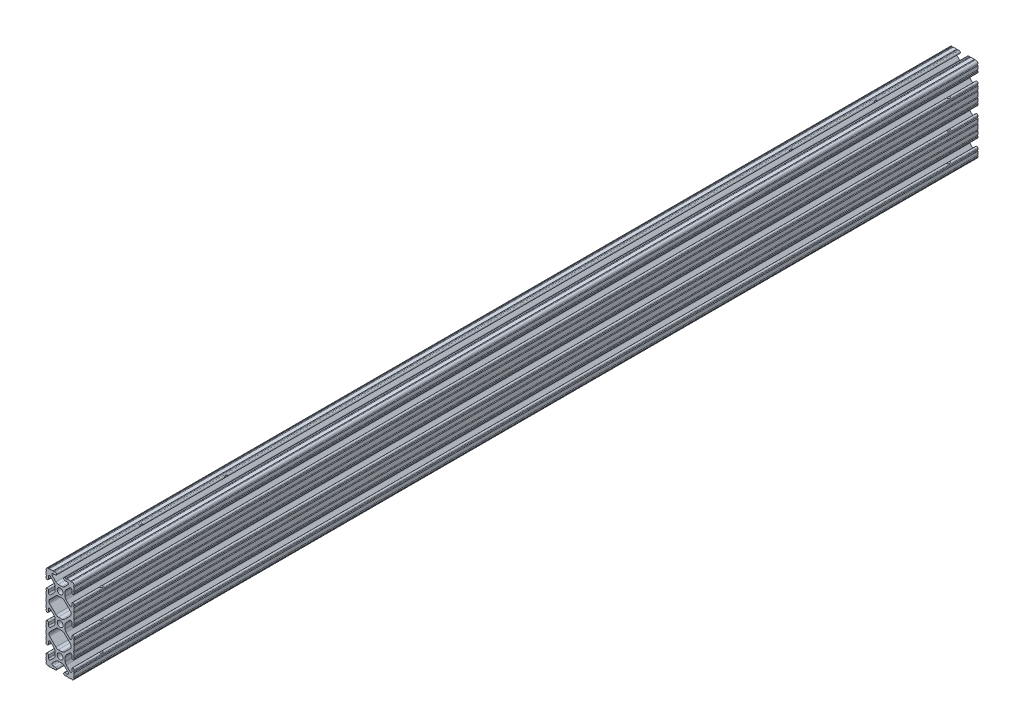
from build123d import *

# Parameters (mm, degrees)
SKETCH1_R               = 2.6035
BOSS_EXTRUDE1_DEPTH     = 406.4
SKETCH2_R               = 3.5
CUT_EXTRUDE1_DEPTH      = 9.19165489
CUT_EXTRUDE1_DEPTH_BACK = 18.20865489
SKETCH4_R               = 3.5
CUT_EXTRUDE3_DEPTH      = 9.19165489
CUT_EXTRUDE3_DEPTH_BACK = 69.008654898


with BuildPart() as part:
    # Sketch1 → Boss-Extrude1 (new body, symmetric)
    with BuildSketch(Plane.XY):
        with BuildLine():
            Line((-12.7, 34.9504), (-12.7, 31.7246))
            ThreePointArc((-12.7, 31.7246), (-12.192, 31.2166), (-12.7, 30.7086))
            Line((-12.7, 30.7086), (-12.7, 29.702307889))
            ThreePointArc((-12.7, 29.702307889), (-11.5951, 28.597407889), (-10.4902, 29.702307889))
            Line((-10.4902, 29.702307889), (-10.4902, 31.874794456))
            ThreePointArc((-10.4902, 31.874794456), (-9.863006367, 32.813456061), (-8.75577951, 32.593214945))
            Line((-8.75577951, 32.593214945), (-5.43843597, 29.275871405))
            ThreePointArc((-5.43843597, 29.275871405), (-4.750182484, 28.245827272), (-4.5085, 27.030807374))
            Line((-4.5085, 27.030807374), (-4.5085, 23.769192626))
            ThreePointArc((-4.5085, 23.769192626), (-4.750182484, 22.554172728), (-5.43843597, 21.524128595))
            Line((-5.43843597, 21.524128595), (-8.75577951, 18.206785055))
            ThreePointArc((-8.75577951, 18.206785055), (-9.863006367, 17.986543939), (-10.4902, 18.925205544))
            Line((-10.4902, 18.925205544), (-10.4902, 21.097692111))
            ThreePointArc((-10.4902, 21.097692111), (-11.5951, 22.202592111), (-12.7, 21.097692111))
            Line((-12.7, 21.097692111), (-12.7, 20.0914))
            ThreePointArc((-12.7, 20.0914), (-12.192, 19.5834), (-12.7, 19.0754))
            Line((-12.7, 19.0754), (-12.7, 15.8496))
            ThreePointArc((-12.7, 15.8496), (-12.192, 15.3416), (-12.7, 14.8336))
            Line((-12.7, 14.8336), (-12.7, 10.5664))
            ThreePointArc((-12.7, 10.5664), (-12.192, 10.0584), (-12.7, 9.5504))
            Line((-12.7, 9.5504), (-12.7, 6.3246))
            ThreePointArc((-12.7, 6.3246), (-12.192000017, 5.8166), (-12.7, 5.3086))
            Line((-12.7, 5.3086), (-12.7, 4.302307889))
            ThreePointArc((-12.7, 4.302307889), (-11.5951, 3.197407889), (-10.4902, 4.302307889))
            Line((-10.4902, 4.302307889), (-10.4902, 6.474794456))
            ThreePointArc((-10.4902, 6.474794456), (-9.863006367, 7.413456061), (-8.75577951, 7.193214945))
            Line((-8.75577951, 7.193214945), (-5.43843597, 3.875871405))
            ThreePointArc((-5.43843597, 3.875871405), (-4.750182484, 2.845827272), (-4.5085, 1.630807374))
            Line((-4.5085, 1.630807374), (-4.5085, -1.630807374))
            ThreePointArc((-4.5085, -1.630807374), (-4.750182484, -2.845827272), (-5.43843597, -3.875871405))
            Line((-5.43843597, -3.875871405), (-8.75577951, -7.193214945))
            ThreePointArc((-8.75577951, -7.193214945), (-9.863006367, -7.413456061), (-10.4902, -6.474794456))
            Line((-10.4902, -6.474794456), (-10.4902, -4.302307889))
            ThreePointArc((-10.4902, -4.302307889), (-11.5951, -3.197407889), (-12.7, -4.302307889))
            Line((-12.7, -4.302307889), (-12.7, -5.3086))
            ThreePointArc((-12.7, -5.3086), (-12.191999983, -5.8166), (-12.7, -6.3246))
            Line((-12.7, -6.3246), (-12.7, -9.5504))
            ThreePointArc((-12.7, -9.5504), (-12.192, -10.0584), (-12.7, -10.5664))
            Line((-12.7, -10.5664), (-12.7, -14.8336))
            ThreePointArc((-12.7, -14.8336), (-12.192, -15.3416), (-12.7, -15.8496))
            Line((-12.7, -15.8496), (-12.7, -19.0754))
            ThreePointArc((-12.7, -19.0754), (-12.192, -19.5834), (-12.7, -20.0914))
            Line((-12.7, -20.0914), (-12.7, -21.097692111))
            ThreePointArc((-12.7, -21.097692111), (-11.5951, -22.202592111), (-10.4902, -21.097692111))
            Line((-10.4902, -21.097692111), (-10.4902, -18.925205544))
            ThreePointArc((-10.4902, -18.925205544), (-9.863006367, -17.986543939), (-8.75577951, -18.206785055))
            Line((-8.75577951, -18.206785055), (-5.43843597, -21.524128595))
            ThreePointArc((-5.43843597, -21.524128595), (-4.750182484, -22.554172728), (-4.5085, -23.769192626))
            Line((-4.5085, -23.769192626), (-4.5085, -27.030807374))
            ThreePointArc((-4.5085, -27.030807374), (-4.750182484, -28.245827272), (-5.43843597, -29.275871405))
            Line((-5.43843597, -29.275871405), (-8.75577951, -32.593214945))
            ThreePointArc((-8.75577951, -32.593214945), (-9.863006367, -32.813456061), (-10.4902, -31.874794456))
            Line((-10.4902, -31.874794456), (-10.4902, -29.702307889))
            ThreePointArc((-10.4902, -29.702307889), (-11.5951, -28.597407889), (-12.7, -29.702307889))
            Line((-12.7, -29.702307889), (-12.7, -30.7086))
            ThreePointArc((-12.7, -30.7086), (-12.192, -31.2166), (-12.7, -31.7246))
            Line((-12.7, -31.7246), (-12.7, -34.9504))
            ThreePointArc((-12.7, -34.9504), (-12.192, -35.4584), (-12.7, -35.9664))
            ThreePointArc((-12.7, -35.9664), (-12.082677406, -37.482677406), (-10.5664, -38.1))
            ThreePointArc((-10.5664, -38.1), (-10.0584, -37.592), (-9.5504, -38.1))
            Line((-9.5504, -38.1), (-6.3246, -38.1))
            ThreePointArc((-6.3246, -38.1), (-5.816599996, -37.592000017), (-5.3086, -38.100000008))
            Line((-5.3086, -38.100000008), (-4.302307889, -38.100000008))
            ThreePointArc((-4.302307889, -38.100000008), (-3.197407889, -36.995100008), (-4.302307889, -35.890200008))
            Line((-4.302307889, -35.890200008), (-6.474794456, -35.890200008))
            ThreePointArc((-6.474794456, -35.890200008), (-7.413456061, -35.263006376), (-7.193214945, -34.155779519))
            Line((-7.193214945, -34.155779519), (-3.875871405, -30.838435978))
            ThreePointArc((-3.875871405, -30.838435978), (-2.845827272, -30.150182493), (-1.630807374, -29.908500008))
            Line((-1.630807374, -29.908500008), (1.630807374, -29.908500008))
            ThreePointArc((1.630807374, -29.908500008), (2.845827272, -30.150182493), (3.875871405, -30.838435978))
            Line((3.875871405, -30.838435978), (7.193214945, -34.155779519))
            ThreePointArc((7.193214945, -34.155779519), (7.413456061, -35.263006376), (6.474794456, -35.890200008))
            Line((6.474794456, -35.890200008), (4.302307889, -35.890200008))
            ThreePointArc((4.302307889, -35.890200008), (3.197407889, -36.995100008), (4.302307889, -38.100000008))
            Line((4.302307889, -38.100000008), (5.3086, -38.100000008))
            ThreePointArc((5.3086, -38.100000008), (5.8166, -37.591999992), (6.3246, -38.100000008))
            Line((6.3246, -38.100000008), (9.5504, -38.100000008))
            ThreePointArc((9.5504, -38.100000008), (10.0584, -37.592000008), (10.5664, -38.100000008))
            ThreePointArc((10.5664, -38.100000008), (12.082677406, -37.482677414), (12.7, -35.966400008))
            ThreePointArc((12.7, -35.966400008), (12.192, -35.458400008), (12.7, -34.950400008))
            Line((12.7, -34.950400008), (12.7, -31.724600008))
            ThreePointArc((12.7, -31.724600008), (12.192, -31.216600008), (12.7, -30.708600008))
            Line((12.7, -30.708600008), (12.7, -29.702307926))
            ThreePointArc((12.7, -29.702307926), (11.5951, -28.597407926), (10.4902, -29.702307926))
            Line((10.4902, -29.702307926), (10.4902, -31.874794464))
            ThreePointArc((10.4902, -31.874794464), (9.863006367, -32.813456069), (8.75577951, -32.593214954))
            Line((8.75577951, -32.593214954), (5.43843597, -29.275871413))
            ThreePointArc((5.43843597, -29.275871413), (4.750182484, -28.245827281), (4.5085, -27.030807383))
            Line((4.5085, -27.030807383), (4.5085, -23.769192634))
            ThreePointArc((4.5085, -23.769192634), (4.750182484, -22.554172736), (5.43843597, -21.524128604))
            Line((5.43843597, -21.524128604), (8.75577951, -18.206785063))
            ThreePointArc((8.75577951, -18.206785063), (9.863006367, -17.986543948), (10.4902, -18.925205553))
            Line((10.4902, -18.925205553), (10.4902, -21.097692067))
            ThreePointArc((10.4902, -21.097692067), (11.5951, -22.202592067), (12.7, -21.097692067))
            Line((12.7, -21.097692067), (12.7, -20.091400008))
            ThreePointArc((12.7, -20.091400008), (12.192, -19.583400008), (12.7, -19.075400008))
            Line((12.7, -19.075400008), (12.7, -15.849600008))
            ThreePointArc((12.7, -15.849600008), (12.192, -15.341600008), (12.7, -14.833600008))
            Line((12.7, -14.833600008), (12.7, -10.566400008))
            ThreePointArc((12.7, -10.566400008), (12.192, -10.058400008), (12.7, -9.550400008))
            Line((12.7, -9.550400008), (12.7, -6.324600008))
            ThreePointArc((12.7, -6.324600008), (12.192000017, -5.816600008), (12.7, -5.308600008))
            Line((12.7, -5.308600008), (12.7, -4.302307897))
            ThreePointArc((12.7, -4.302307897), (11.5951, -3.197407897), (10.4902, -4.302307897))
            Line((10.4902, -4.302307897), (10.4902, -6.474794464))
            ThreePointArc((10.4902, -6.474794464), (9.863006367, -7.413456069), (8.75577951, -7.193214954))
            Line((8.75577951, -7.193214954), (5.43843597, -3.875871413))
            ThreePointArc((5.43843597, -3.875871413), (4.750182484, -2.845827281), (4.5085, -1.630807383))
            Line((4.5085, -1.630807383), (4.5085, 1.630807366))
            ThreePointArc((4.5085, 1.630807366), (4.750182484, 2.845827264), (5.43843597, 3.875871396))
            Line((5.43843597, 3.875871396), (8.75577951, 7.193214937))
            ThreePointArc((8.75577951, 7.193214937), (9.863006367, 7.413456052), (10.4902, 6.474794447))
            Line((10.4902, 6.474794447), (10.4902, 4.302307881))
            ThreePointArc((10.4902, 4.302307881), (11.5951, 3.197407881), (12.7, 4.302307881))
            Line((12.7, 4.302307881), (12.7, 5.308599992))
            ThreePointArc((12.7, 5.308599992), (12.191999983, 5.816599992), (12.7, 6.324599992))
            Line((12.7, 6.324599992), (12.7, 9.550399992))
            ThreePointArc((12.7, 9.550399992), (12.192, 10.058399992), (12.7, 10.566399992))
            Line((12.7, 10.566399992), (12.7, 14.833599992))
            ThreePointArc((12.7, 14.833599992), (12.192, 15.341599992), (12.7, 15.849599992))
            Line((12.7, 15.849599992), (12.7, 19.075399992))
            ThreePointArc((12.7, 19.075399992), (12.192, 19.583399992), (12.7, 20.091399992))
            Line((12.7, 20.091399992), (12.7, 21.097692074))
            ThreePointArc((12.7, 21.097692074), (11.5951, 22.202592074), (10.4902, 21.097692074))
            Line((10.4902, 21.097692074), (10.4902, 18.925205536))
            ThreePointArc((10.4902, 18.925205536), (9.863006367, 17.986543931), (8.75577951, 18.206785046))
            Line((8.75577951, 18.206785046), (5.43843597, 21.524128587))
            ThreePointArc((5.43843597, 21.524128587), (4.750182484, 22.554172719), (4.5085, 23.769192617))
            Line((4.5085, 23.769192617), (4.5085, 27.030807366))
            ThreePointArc((4.5085, 27.030807366), (4.750182484, 28.245827264), (5.43843597, 29.275871396))
            Line((5.43843597, 29.275871396), (8.75577951, 32.593214937))
            ThreePointArc((8.75577951, 32.593214937), (9.863006367, 32.813456052), (10.4902, 31.874794447))
            Line((10.4902, 31.874794447), (10.4902, 29.702307881))
            ThreePointArc((10.4902, 29.702307881), (11.5951, 28.597407881), (12.7, 29.702307881))
            Line((12.7, 29.702307881), (12.7, 30.708599992))
            ThreePointArc((12.7, 30.708599992), (12.192, 31.216599992), (12.7, 31.724599992))
            Line((12.7, 31.724599992), (12.7, 34.9504))
            ThreePointArc((12.7, 34.9504), (12.192, 35.4584), (12.7, 35.9664))
            ThreePointArc((12.7, 35.9664), (12.082677406, 37.482677406), (10.5664, 38.1))
            ThreePointArc((10.5664, 38.1), (10.0584, 37.592), (9.5504, 38.1))
            Line((9.5504, 38.1), (6.3246, 38.1))
            ThreePointArc((6.3246, 38.1), (5.8166, 37.591999983), (5.3086, 38.1))
            Line((5.3086, 38.1), (4.302307889, 38.1))
            ThreePointArc((4.302307889, 38.1), (3.197407889, 36.9951), (4.302307889, 35.8902))
            Line((4.302307889, 35.8902), (6.474794456, 35.8902))
            ThreePointArc((6.474794456, 35.8902), (7.413456061, 35.263006367), (7.193214945, 34.15577951))
            Line((7.193214945, 34.15577951), (3.875871405, 30.83843597))
            ThreePointArc((3.875871405, 30.83843597), (2.845827272, 30.150182484), (1.630807374, 29.9085))
            Line((1.630807374, 29.9085), (-1.630807374, 29.9085))
            ThreePointArc((-1.630807374, 29.9085), (-2.845827272, 30.150182484), (-3.875871405, 30.83843597))
            Line((-3.875871405, 30.83843597), (-7.193214945, 34.15577951))
            ThreePointArc((-7.193214945, 34.15577951), (-7.413456061, 35.263006367), (-6.474794456, 35.8902))
            Line((-6.474794456, 35.8902), (-4.302307889, 35.8902))
            ThreePointArc((-4.302307889, 35.8902), (-3.197407889, 36.9951), (-4.302307889, 38.1))
            Line((-4.302307889, 38.1), (-5.3086, 38.1))
            ThreePointArc((-5.3086, 38.1), (-5.8166, 37.592000017), (-6.3246, 38.1))
            Line((-6.3246, 38.1), (-9.5504, 38.1))
            ThreePointArc((-9.5504, 38.1), (-10.0584, 37.592), (-10.5664, 38.1))
            ThreePointArc((-10.5664, 38.1), (-12.082677406, 37.482677406), (-12.7, 35.9664))
            ThreePointArc((-12.7, 35.9664), (-12.192, 35.4584), (-12.7, 34.9504))
        make_face()
        with Locations((0, -25.4)):
            Circle(SKETCH1_R, mode=Mode.SUBTRACT)
        Circle(SKETCH1_R, mode=Mode.SUBTRACT)
        with Locations((0, 25.4)):
            Circle(SKETCH1_R, mode=Mode.SUBTRACT)
        with BuildLine():
            Line((-9.9314, -12.146268083), (-9.9314, -13.253731917))
            ThreePointArc((-9.9314, -13.253731917), (-9.811525488, -13.856381786), (-9.470151759, -14.367283676))
            Line((-9.470151759, -14.367283676), (-3.875871405, -19.96156403))
            ThreePointArc((-3.875871405, -19.96156403), (-2.845827272, -20.649817516), (-1.630807374, -20.8915))
            Line((-1.630807374, -20.8915), (1.630807374, -20.8915))
            ThreePointArc((1.630807374, -20.8915), (2.845827272, -20.649817516), (3.875871405, -19.96156403))
            Line((3.875871405, -19.96156403), (9.470151759, -14.367283676))
            ThreePointArc((9.470151759, -14.367283676), (9.811525488, -13.856381786), (9.9314, -13.253731917))
            Line((9.9314, -13.253731917), (9.9314, -12.146268083))
            ThreePointArc((9.9314, -12.146268083), (9.811525488, -11.543618214), (9.470151759, -11.032716324))
            Line((9.470151759, -11.032716324), (3.875871405, -5.43843597))
            ThreePointArc((3.875871405, -5.43843597), (2.845827272, -4.750182484), (1.630807374, -4.5085))
            Line((1.630807374, -4.5085), (-1.630807374, -4.5085))
            ThreePointArc((-1.630807374, -4.5085), (-2.845827272, -4.750182484), (-3.875871405, -5.43843597))
            Line((-3.875871405, -5.43843597), (-9.470151759, -11.032716324))
            ThreePointArc((-9.470151759, -11.032716324), (-9.811525488, -11.543618214), (-9.9314, -12.146268083))
        make_face(mode=Mode.SUBTRACT)
        with BuildLine():
            Line((-9.9314, 13.253731917), (-9.9314, 12.146268083))
            ThreePointArc((-9.9314, 12.146268083), (-9.811525488, 11.543618214), (-9.470151759, 11.032716324))
            Line((-9.470151759, 11.032716324), (-3.875871405, 5.43843597))
            ThreePointArc((-3.875871405, 5.43843597), (-2.845827272, 4.750182484), (-1.630807374, 4.5085))
            Line((-1.630807374, 4.5085), (1.630807374, 4.5085))
            ThreePointArc((1.630807374, 4.5085), (2.845827272, 4.750182484), (3.875871405, 5.43843597))
            Line((3.875871405, 5.43843597), (9.470151759, 11.032716324))
            ThreePointArc((9.470151759, 11.032716324), (9.811525488, 11.543618214), (9.9314, 12.146268083))
            Line((9.9314, 12.146268083), (9.9314, 13.253731917))
            ThreePointArc((9.9314, 13.253731917), (9.811525488, 13.856381786), (9.470151759, 14.367283676))
            Line((9.470151759, 14.367283676), (3.875871405, 19.96156403))
            ThreePointArc((3.875871405, 19.96156403), (2.845827272, 20.649817516), (1.630807374, 20.8915))
            Line((1.630807374, 20.8915), (-1.630807374, 20.8915))
            ThreePointArc((-1.630807374, 20.8915), (-2.845827272, 20.649817516), (-3.875871405, 19.96156403))
            Line((-3.875871405, 19.96156403), (-9.470151759, 14.367283676))
            ThreePointArc((-9.470151759, 14.367283676), (-9.811525488, 13.856381786), (-9.9314, 13.253731917))
        make_face(mode=Mode.SUBTRACT)
    extrude(amount=BOSS_EXTRUDE1_DEPTH, both=True)

    # Sketch2 → Cut-Extrude1 (cut, two sides)
    with BuildSketch(Plane(origin=(4.5085, 0, 0), x_dir=(0, 0, -1), z_dir=(1, 0, 0))) as cut_extrude1_sk:
        with Locations((-381, 25.4)):
            Circle(SKETCH2_R)
        with Locations((-381, 0)):
            Circle(SKETCH2_R)
        with Locations((-381, -25.4)):
            Circle(SKETCH2_R)
        with Locations((381, 25.4)):
            Circle(SKETCH2_R)
        with Locations((381, 0)):
            Circle(SKETCH2_R)
        with Locations((381, -25.4)):
            Circle(SKETCH2_R)
    extrude(amount=CUT_EXTRUDE1_DEPTH, mode=Mode.SUBTRACT)
    extrude(cut_extrude1_sk.sketch, amount=-CUT_EXTRUDE1_DEPTH_BACK, mode=Mode.SUBTRACT)

    # Sketch4 → Cut-Extrude3 (cut, two sides)
    with BuildSketch(Plane.XZ.offset(29.908500008)) as cut_extrude3_sk:
        with Locations((0, 330.2)):
            Circle(SKETCH4_R)
        with Locations((0, -330.2)):
            Circle(SKETCH4_R)
        with Locations((0, 254)):
            Circle(SKETCH4_R)
        with Locations((0, -254)):
            Circle(SKETCH4_R)
    extrude(amount=CUT_EXTRUDE3_DEPTH, mode=Mode.SUBTRACT)
    extrude(cut_extrude3_sk.sketch, amount=-CUT_EXTRUDE3_DEPTH_BACK, mode=Mode.SUBTRACT)


solid = part.part
